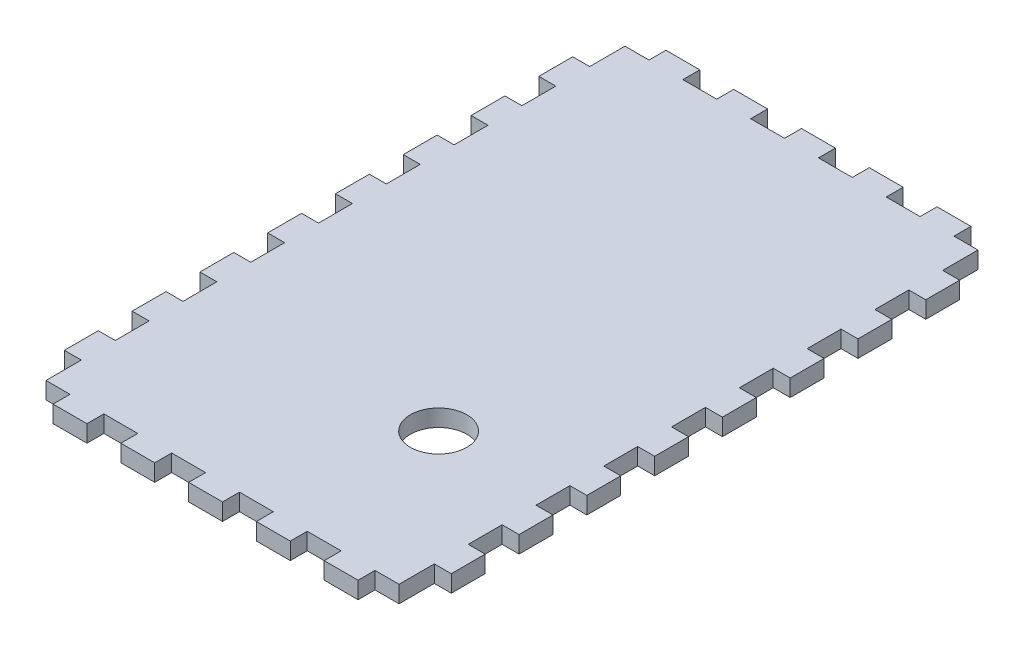
from build123d import *

# Parameters (mm, degrees)
SKETCH3_W           = 125
SKETCH3_H           = 205
BOSS_EXTRUDE1_DEPTH = 6
SKETCH5_W           = 12
SKETCH5_H           = 6
SKETCH5_W_2         = 6
SKETCH5_H_2         = 12
BOSS_EXTRUDE2_DEPTH = 6
SKETCH6_R           = 10
CUT_EXTRUDE1_DEPTH  = 6


with BuildPart() as part:
    # Sketch3 → Boss-Extrude1 (new body)
    with BuildSketch(Plane(origin=(0, 0, 0), x_dir=(1, 0, 0), z_dir=(0, 1, 0))):
        Rectangle(SKETCH3_W, SKETCH3_H)
    extrude(amount=BOSS_EXTRUDE1_DEPTH)

    # Sketch5 → Boss-Extrude2 (add)
    with BuildSketch(Plane(origin=(0, 6, 0), x_dir=(1, 0, 0), z_dir=(0, 1, 0))):
        with Locations((24, -105.5)):
            Rectangle(SKETCH5_W, SKETCH5_H)
        with Locations((0, -105.5)):
            Rectangle(SKETCH5_W, SKETCH5_H)
        with Locations((-65.5, -84)):
            Rectangle(SKETCH5_W_2, SKETCH5_H_2)
        with Locations((-65.5, -60)):
            Rectangle(SKETCH5_W_2, SKETCH5_H_2)
        with Locations((-65.5, -12)):
            Rectangle(SKETCH5_W_2, SKETCH5_H_2)
        with Locations((65.5, -84)):
            Rectangle(SKETCH5_W_2, SKETCH5_H_2)
        with Locations((65.5, -36)):
            Rectangle(SKETCH5_W_2, SKETCH5_H_2)
        with Locations((65.5, -12)):
            Rectangle(SKETCH5_W_2, SKETCH5_H_2)
        with Locations((65.5, 12)):
            Rectangle(SKETCH5_W_2, SKETCH5_H_2)
        with Locations((65.5, 36)):
            Rectangle(SKETCH5_W_2, SKETCH5_H_2)
        with Locations((65.5, 84)):
            Rectangle(SKETCH5_W_2, SKETCH5_H_2)
        with Locations((24, 105.5)):
            Rectangle(SKETCH5_W, SKETCH5_H)
        with Locations((0, 105.5)):
            Rectangle(SKETCH5_W, SKETCH5_H)
        with Locations((-24, 105.5)):
            Rectangle(SKETCH5_W, SKETCH5_H)
        with Locations((-48, 105.5)):
            Rectangle(SKETCH5_W, SKETCH5_H)
        with Locations((-65.5, 36)):
            Rectangle(SKETCH5_W_2, SKETCH5_H_2)
        with Locations((-65.5, 12)):
            Rectangle(SKETCH5_W_2, SKETCH5_H_2)
        with Locations((48, -105.5)):
            Rectangle(SKETCH5_W, SKETCH5_H)
        with Locations((-24, -105.5)):
            Rectangle(SKETCH5_W, SKETCH5_H)
        with Locations((-48, -105.5)):
            Rectangle(SKETCH5_W, SKETCH5_H)
        with Locations((-65.5, -36)):
            Rectangle(SKETCH5_W_2, SKETCH5_H_2)
        with Locations((65.5, -60)):
            Rectangle(SKETCH5_W_2, SKETCH5_H_2)
        with Locations((65.5, 60)):
            Rectangle(SKETCH5_W_2, SKETCH5_H_2)
        with Locations((48, 105.5)):
            Rectangle(SKETCH5_W, SKETCH5_H)
        with Locations((-65.5, 84)):
            Rectangle(SKETCH5_W_2, SKETCH5_H_2)
        with Locations((-65.5, 60)):
            Rectangle(SKETCH5_W_2, SKETCH5_H_2)
    extrude(amount=-BOSS_EXTRUDE2_DEPTH)

    # Sketch6 → Cut-Extrude1 (cut)
    with BuildSketch(Plane(origin=(0, 6, 0), x_dir=(1, 0, 0), z_dir=(0, 1, 0))):
        with Locations((22.512507822, -48.5)):
            Circle(SKETCH6_R)
    extrude(amount=-CUT_EXTRUDE1_DEPTH, mode=Mode.SUBTRACT)


solid = part.part
